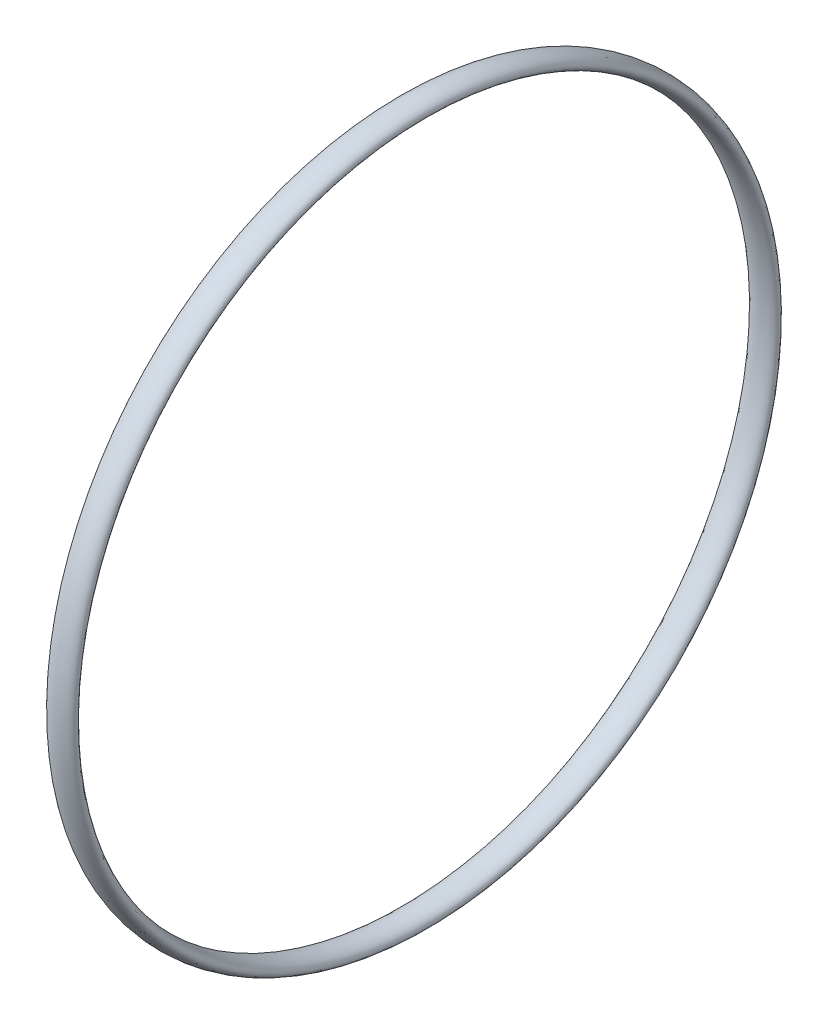
from build123d import *

# Parameters (mm, degrees)
SKETCH3_RX = 0.75
SKETCH3_RY = 0.375


with BuildPart() as part:
    # Sketch3 → Revolve1 (revolve)
    with BuildSketch(Plane(origin=(3.207574377, 0.884557104, -15.792659912), x_dir=(-0.858649975, -0.512562406, 0), z_dir=(0, 0, -1))):
        with Locations(Location((-7.373192147, 18.609569347), (0, 0, 30.834661532))):
            Ellipse(SKETCH3_RX, SKETCH3_RY)
    revolve(axis=Axis((-7.348665074, 2.165912654, -15.792659912), (1, 0, 0)))


solid = part.part
